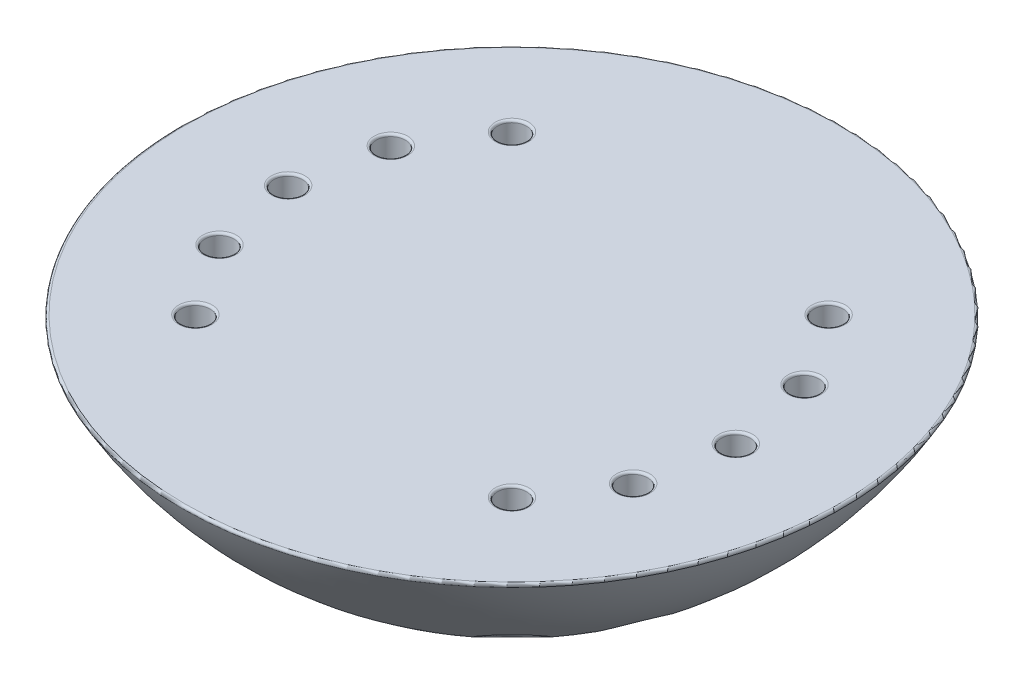
from build123d import *

# Parameters (mm, degrees)
TOP_CUT_SKETCH_W                = 443.917863005
TOP_CUT_SKETCH_H                = 367.972648153
TOP_CUT_DEPTH                   = 97.25
TOP_CUT_DEPTH_BACK              = 53.75
BOLT_HOLE_CUT_SKETCH_R          = 3.15625
BOLT_HOLE_CUT_DEPTH             = 97.25
BOLT_HEAD_CUT_SKETCH_R          = 5.4375
BOLT_HEAD_CUT_DEPTH             = 186.75
CIRPATTERN2_COUNT               = 3
CIRPATTERN2_ANGLE               = 45
CIRPATTERN2_THE_OTHER_WAY_COUNT = 3
CIRPATTERN2_THE_OTHER_WAY_ANGLE = 45
MIRROR1_COPY_1_SKETCH_R         = 3.15625
MIRROR1_COPY_1_DEPTH            = 97.25
MIRROR1_COPY_2_SKETCH_R         = 3.15625
MIRROR1_COPY_2_DEPTH            = 97.25
MIRROR1_COPY_3_SKETCH_R         = 5.4375
MIRROR1_COPY_3_DEPTH            = 186.75
MIRROR1_COPY_4_SKETCH_R         = 5.4375
MIRROR1_COPY_4_DEPTH            = 186.75
MIRROR1_COPY_5_SKETCH_R         = 3.15625
MIRROR1_COPY_5_DEPTH            = 97.25
MIRROR1_COPY_6_SKETCH_R         = 3.15625
MIRROR1_COPY_6_DEPTH            = 97.25
MIRROR1_COPY_7_SKETCH_R         = 5.4375
MIRROR1_COPY_7_DEPTH            = 186.75
MIRROR1_COPY_8_SKETCH_R         = 5.4375
MIRROR1_COPY_8_DEPTH            = 186.75
FILLET2_R                       = 0.5


with BuildPart() as part:
    # Main Revolve Sketch → Main Revolve (revolve)
    with BuildSketch(Plane.XY):
        with BuildLine():
            Line((0, 0), (0, 13.75))
            Line((0, 13.75), (0, 96.25))
            ThreePointArc((0, 96.25), (-58.336309448, 72.086309448), (-82.5, 13.75))
            Line((-82.5, 13.75), (-82.5, -13.75))
            ThreePointArc((-82.5, -13.75), (-58.336309448, -72.086309448), (0, -96.25))
            Line((0, -96.25), (0, -13.75))
            Line((0, -13.75), (0, 0))
        make_face()
    revolve(axis=Axis((0, 13.75, 0), (0, 1, 0)))

    # Top Cut Sketch → Top Cut (cut, two sides)
    with BuildSketch(Plane(origin=(0, 0, 0), x_dir=(1, 0, 0), z_dir=(0, 1, 0))) as top_cut_sk:
        with Locations((35.712333175, -10.849316407)):
            Rectangle(TOP_CUT_SKETCH_W, TOP_CUT_SKETCH_H)
    extrude(amount=TOP_CUT_DEPTH, mode=Mode.SUBTRACT)
    extrude(top_cut_sk.sketch, amount=-TOP_CUT_DEPTH_BACK, mode=Mode.SUBTRACT)

    # Bolt Hole Cut Sketch → Bolt Hole Cut (cut, through all)
    with BuildSketch(Plane(origin=(0, 0, 0), x_dir=(1, 0, 0), z_dir=(0, 1, 0))):
        with Locations((-48.75, 0)):
            Circle(BOLT_HOLE_CUT_SKETCH_R)
    bolt_hole_cut = extrude(amount=-BOLT_HOLE_CUT_DEPTH, mode=Mode.SUBTRACT)

    # Bolt Head Cut Sketch → Bolt Head Cut (cut)
    with BuildSketch(Plane(origin=(0, -250, 0), x_dir=(1, 0, 0), z_dir=(0, 1, 0))):
        with Locations((-48.75, 0)):
            Circle(BOLT_HEAD_CUT_SKETCH_R)
    bolt_head_cut = extrude(amount=BOLT_HEAD_CUT_DEPTH, mode=Mode.SUBTRACT)

    # CirPattern2: Bolt Hole Cut, Bolt Head Cut ×3 about axis
    cirpattern2_axis = Axis((0, 0, 0), (0, 1, 0))
    for i in range(1, CIRPATTERN2_COUNT):
        add(bolt_hole_cut.rotate(cirpattern2_axis, i * CIRPATTERN2_ANGLE / (CIRPATTERN2_COUNT - 1)), mode=Mode.SUBTRACT)
        add(bolt_head_cut.rotate(cirpattern2_axis, i * CIRPATTERN2_ANGLE / (CIRPATTERN2_COUNT - 1)), mode=Mode.SUBTRACT)

    # CirPattern2 the other way: Bolt Hole Cut, Bolt Head Cut ×3 about axis
    cirpattern2_the_other_way_axis = Axis((0, 0, 0), (0, -1, 0))
    for i in range(1, CIRPATTERN2_THE_OTHER_WAY_COUNT):
        add(bolt_hole_cut.rotate(cirpattern2_the_other_way_axis, i * CIRPATTERN2_THE_OTHER_WAY_ANGLE / (CIRPATTERN2_THE_OTHER_WAY_COUNT - 1)), mode=Mode.SUBTRACT)
        add(bolt_head_cut.rotate(cirpattern2_the_other_way_axis, i * CIRPATTERN2_THE_OTHER_WAY_ANGLE / (CIRPATTERN2_THE_OTHER_WAY_COUNT - 1)), mode=Mode.SUBTRACT)

    # Mirror1: Bolt Hole Cut, Bolt Head Cut across plane
    add(bolt_hole_cut.mirror(Plane(origin=(0, 0, 0), x_dir=(0, 0, 1), z_dir=(1, 0, 0))), mode=Mode.SUBTRACT)
    add(bolt_head_cut.mirror(Plane(origin=(0, 0, 0), x_dir=(0, 0, 1), z_dir=(1, 0, 0))), mode=Mode.SUBTRACT)

    # Mirror1 copy 1 sketch → Mirror1 copy 1 (cut, through all)
    with BuildSketch(Plane(origin=(0, 0, 0), x_dir=(-0.923879533, 0, -0.382683432), z_dir=(0, 1, 0))):
        with Locations((-48.75, 0)):
            Circle(MIRROR1_COPY_1_SKETCH_R)
    extrude(amount=-MIRROR1_COPY_1_DEPTH, mode=Mode.SUBTRACT)

    # Mirror1 copy 2 sketch → Mirror1 copy 2 (cut, through all)
    with BuildSketch(Plane(origin=(0, 0, 0), x_dir=(-0.707106781, 0, -0.707106781), z_dir=(0, 1, 0))):
        with Locations((-48.75, 0)):
            Circle(MIRROR1_COPY_2_SKETCH_R)
    extrude(amount=-MIRROR1_COPY_2_DEPTH, mode=Mode.SUBTRACT)

    # Mirror1 copy 3 sketch → Mirror1 copy 3 (cut)
    with BuildSketch(Plane(origin=(0, -250, 0), x_dir=(-0.923879533, 0, -0.382683432), z_dir=(0, 1, 0))):
        with Locations((-48.75, 0)):
            Circle(MIRROR1_COPY_3_SKETCH_R)
    extrude(amount=MIRROR1_COPY_3_DEPTH, mode=Mode.SUBTRACT)

    # Mirror1 copy 4 sketch → Mirror1 copy 4 (cut)
    with BuildSketch(Plane(origin=(0, -250, 0), x_dir=(-0.707106781, 0, -0.707106781), z_dir=(0, 1, 0))):
        with Locations((-48.75, 0)):
            Circle(MIRROR1_COPY_4_SKETCH_R)
    extrude(amount=MIRROR1_COPY_4_DEPTH, mode=Mode.SUBTRACT)

    # Mirror1 copy 5 sketch → Mirror1 copy 5 (cut, through all)
    with BuildSketch(Plane(origin=(0, 0, 0), x_dir=(-0.923879533, 0, 0.382683432), z_dir=(0, 1, 0))):
        with Locations((-48.75, 0)):
            Circle(MIRROR1_COPY_5_SKETCH_R)
    extrude(amount=-MIRROR1_COPY_5_DEPTH, mode=Mode.SUBTRACT)

    # Mirror1 copy 6 sketch → Mirror1 copy 6 (cut, through all)
    with BuildSketch(Plane(origin=(0, 0, 0), x_dir=(-0.707106781, 0, 0.707106781), z_dir=(0, 1, 0))):
        with Locations((-48.75, 0)):
            Circle(MIRROR1_COPY_6_SKETCH_R)
    extrude(amount=-MIRROR1_COPY_6_DEPTH, mode=Mode.SUBTRACT)

    # Mirror1 copy 7 sketch → Mirror1 copy 7 (cut)
    with BuildSketch(Plane(origin=(0, -250, 0), x_dir=(-0.923879533, 0, 0.382683432), z_dir=(0, 1, 0))):
        with Locations((-48.75, 0)):
            Circle(MIRROR1_COPY_7_SKETCH_R)
    extrude(amount=MIRROR1_COPY_7_DEPTH, mode=Mode.SUBTRACT)

    # Mirror1 copy 8 sketch → Mirror1 copy 8 (cut)
    with BuildSketch(Plane(origin=(0, -250, 0), x_dir=(-0.707106781, 0, 0.707106781), z_dir=(0, 1, 0))):
        with Locations((-48.75, 0)):
            Circle(MIRROR1_COPY_8_SKETCH_R)
    extrude(amount=MIRROR1_COPY_8_DEPTH, mode=Mode.SUBTRACT)

    # Fillet2
    fillet2_edges = [part.edges().sort_by_distance(p)[0] for p in [
        (38.316348706, -75.959041495, -38.316348706),
        (50.062722168, -75.959041495, -20.736658491),
        (38.316348706, -75.959041495, 38.316348706),
        (50.062722168, -75.959041495, 20.736658491),
        (54.1875, -75.959041495, 0),
        (72.154348448, -53.75, 0),
        (-51.90625, -53.75, 0),
        (-48.791711652, -80.052746608, 5.437339997),
        (-36.703261361, -53.75, -36.703261361),
        (-47.955121984, -53.75, -19.863661911),
        (-36.703261361, -53.75, 36.703261361),
        (-47.955121984, -53.75, 19.863661911),
        (-38.316348706, -75.959041495, -38.316348706),
        (-50.062722168, -75.959041495, -20.736658491),
        (-38.316348706, -75.959041495, 38.316348706),
        (-50.062722168, -75.959041495, 20.736658491),
        (36.703261361, -53.75, -36.703261361),
        (47.955121984, -53.75, -19.863661911),
        (36.703261361, -53.75, 36.703261361),
        (47.955121984, -53.75, 19.863661911),
        (51.90625, -53.75, 0),
    ]]
    fillet(fillet2_edges, radius=FILLET2_R)


solid = part.part
